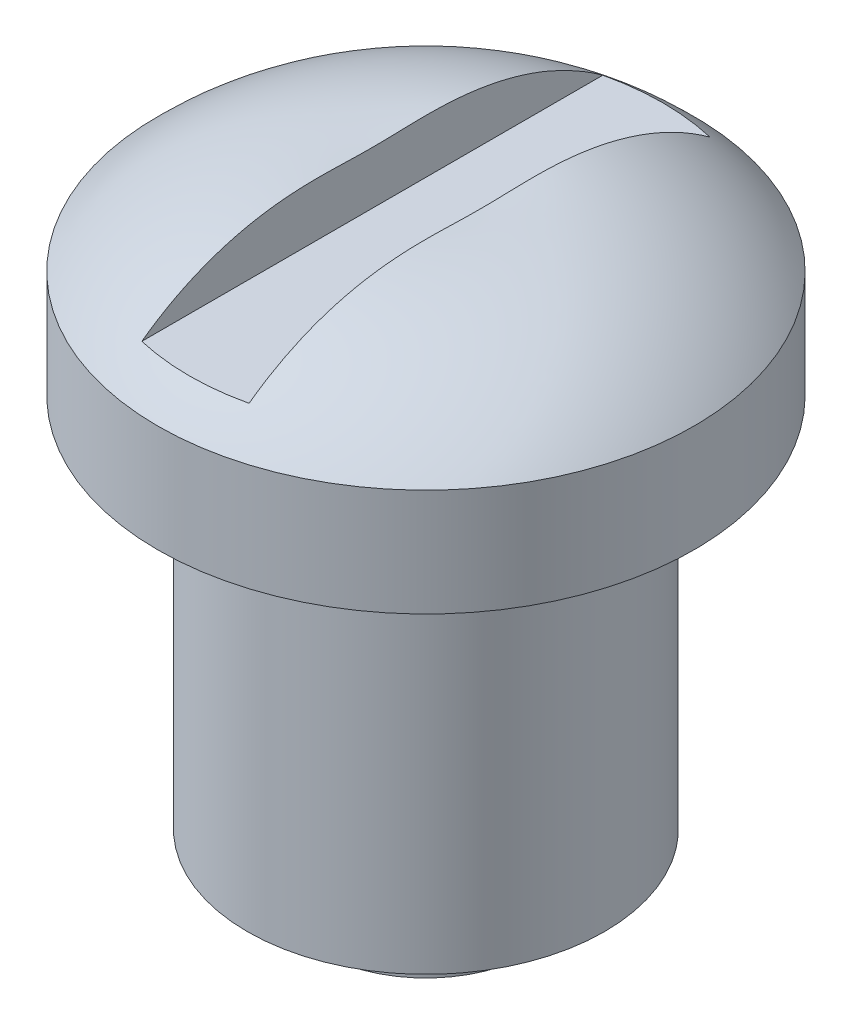
from build123d import *

# Parameters (mm, degrees)
SKETCH2_R           = 1
BOSS_EXTRUDE1_DEPTH = 1
SKETCH3_W           = 2
SKETCH3_H           = 1
CUT_EXTRUDE1_DEPTH  = 5


with BuildPart() as part:
    # Sketch1 → Revolve1 (revolve)
    with BuildSketch(Plane.XY):
        with BuildLine():
            Line((0, 5), (0, -5))
            Line((0, -5), (2, -5))
            Line((2, -5), (2, -4))
            Line((2, -4), (3.33, -4))
            Line((3.33, -4), (3.33, 3))
            Line((3.33, 3), (5, 3))
            Line((5, 3), (5, 5))
            ThreePointArc((5, 5), (3.168263504, 6.198702678), (1, 6.5))
            Line((1, 6.5), (1, 5.5))
            Line((1, 5.5), (0, 5.5))
            Line((0, 5.5), (0, 5))
        make_face()
    revolve(axis=Axis((0, 5, 0), (0, -1, 0)))

    # Sketch2 → Boss-Extrude1 (add)
    with BuildSketch(Plane(origin=(0, 5.5, 0), x_dir=(1, 0, 0), z_dir=(0, 1, 0))):
        Circle(SKETCH2_R)
    extrude(amount=BOSS_EXTRUDE1_DEPTH)

    # Sketch3 → Cut-Extrude1 (cut, symmetric)
    with BuildSketch(Plane.XY):
        with Locations((0, 6.01705679)):
            Rectangle(SKETCH3_W, SKETCH3_H)
    extrude(amount=CUT_EXTRUDE1_DEPTH, both=True, mode=Mode.SUBTRACT)


solid = part.part
